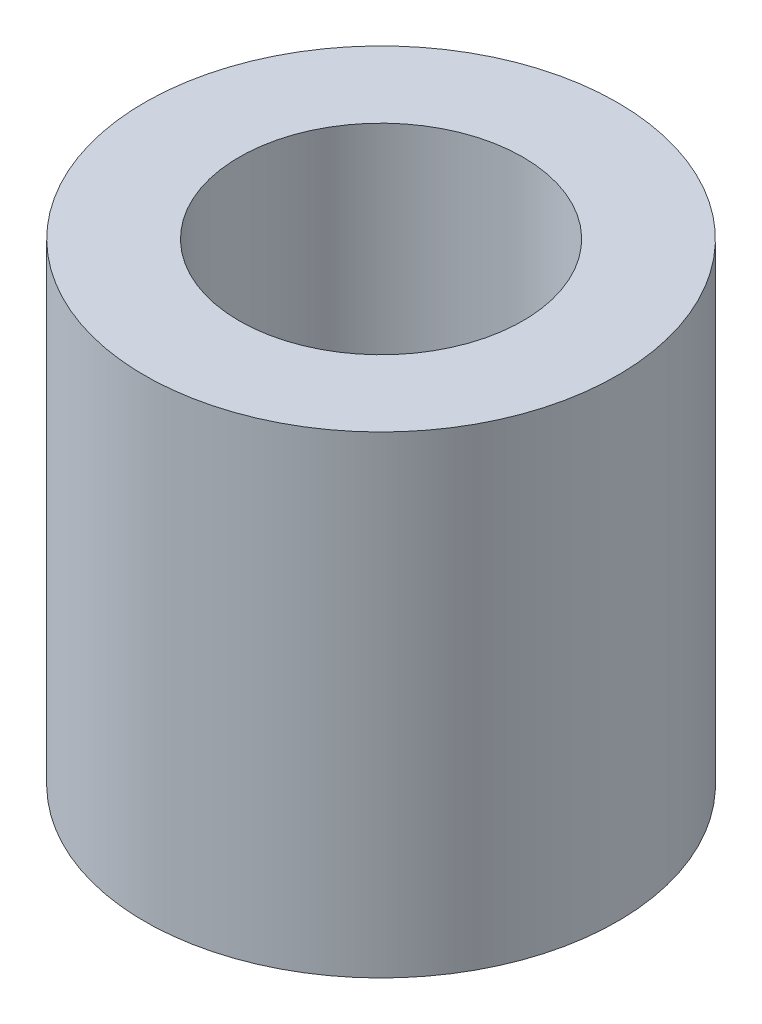
from build123d import *

# Parameters (mm, degrees)
SKETCH1_W = 1
SKETCH1_H = 5


with BuildPart() as part:
    # Sketch1 → Revolve1 (revolve)
    with BuildSketch(Plane.XY):
        with Locations((2, 2.5)):
            Rectangle(SKETCH1_W, SKETCH1_H)
    revolve(axis=Axis((0, 0, 0), (0, 1, 0)))


solid = part.part
